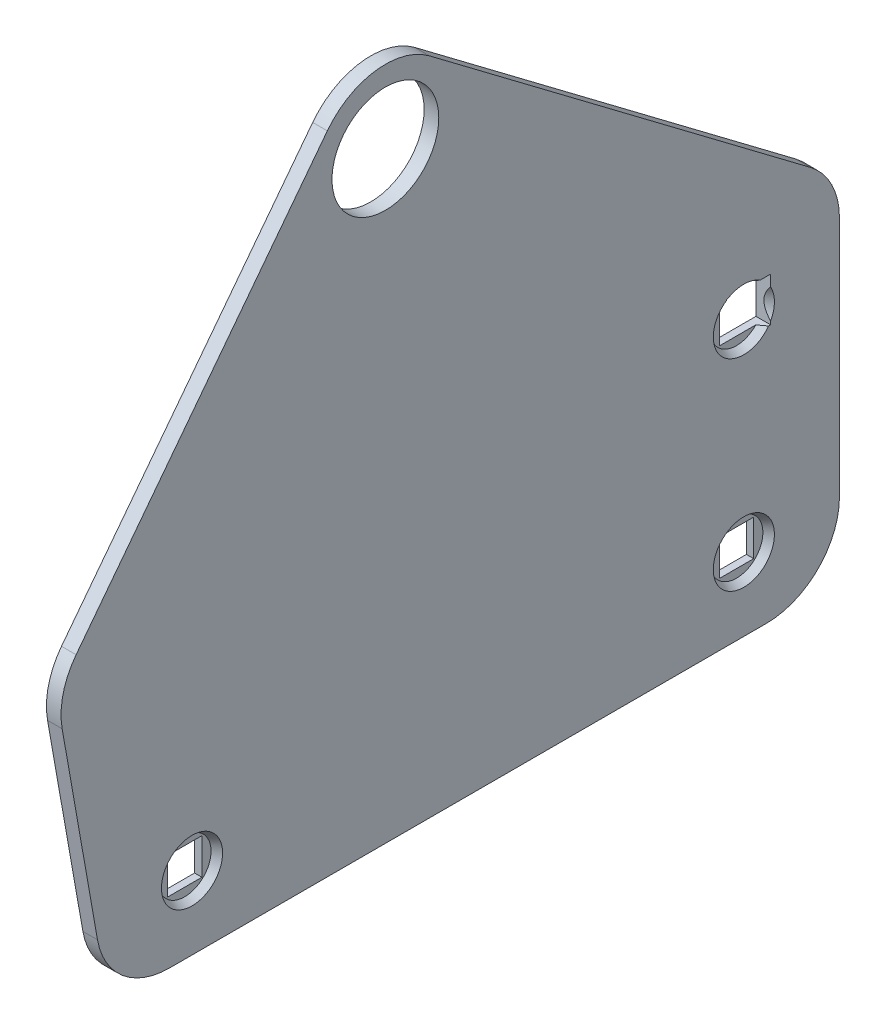
from build123d import *

# Parameters (mm, degrees)
SKETCH1_R           = 3.65
SKETCH1_W           = 3
SKETCH1_H           = 3
SKETCH1_W_2         = 2.35
SKETCH1_H_2         = 2.46
BOSS_EXTRUDE1_DEPTH = 1
SKETCH3_R           = 2.09
CUT_EXTRUDE1_DEPTH  = 0.5
CUT_EXTRUDE1_TAPER  = 30


with BuildPart() as part:
    # Sketch1 → Boss-Extrude1 (new body)
    with BuildSketch(Plane(origin=(0, 0, 0), x_dir=(0, 0, -1), z_dir=(1, 0, 0))):
        with BuildLine():
            Line((-20.402250922, 0), (20.402250922, 0))
            ThreePointArc((20.402250922, 0), (23.937784828, 1.464466094), (25.402250922, 5))
            Line((25.402250922, 5), (25.402250922, 21.50709196))
            ThreePointArc((25.402250922, 21.50709196), (24.87692273, 23.738081025), (23.411326038, 25.50026951))
            Line((23.411326038, 25.50026951), (-2.635195634, 45.127731407))
            ThreePointArc((-2.635195634, 45.127731407), (-6.321071977, 46.088536103), (-9.61416456, 44.174281334))
            Line((-9.61416456, 44.174281334), (-26.788641191, 21.74435991))
            ThreePointArc((-26.788641191, 21.74435991), (-27.676067974, 19.890565251), (-27.742786146, 17.836391544))
            Line((-27.742786146, 17.836391544), (-25.326289687, 4.131759112))
            ThreePointArc((-25.326289687, 4.131759112), (-23.61618897, 1.169777784), (-20.402250922, 0))
        make_face()
        with Locations((-5.64427075, 41.134553857)):
            Circle(SKETCH1_R, mode=Mode.SUBTRACT)
        with Locations((19.19182941, 19.04)):
            Rectangle(SKETCH1_W, SKETCH1_H, mode=Mode.SUBTRACT)
        with Locations((18.865, 5)):
            Rectangle(SKETCH1_W_2, SKETCH1_H_2, mode=Mode.SUBTRACT)
        with Locations((-18.865, 5)):
            Rectangle(SKETCH1_W_2, SKETCH1_H_2, mode=Mode.SUBTRACT)
    extrude(amount=BOSS_EXTRUDE1_DEPTH)

    # Sketch3 → Cut-Extrude1 (cut)
    with BuildSketch(Plane(origin=(1, 0, 0), x_dir=(0, 0, -1), z_dir=(1, 0, 0))):
        with Locations((-18.865, 5)):
            Circle(SKETCH3_R)
        with Locations((18.865, 5)):
            Circle(SKETCH3_R)
        with Locations((18.865, 18.77)):
            Circle(SKETCH3_R)
    extrude(amount=-CUT_EXTRUDE1_DEPTH, taper=CUT_EXTRUDE1_TAPER, mode=Mode.SUBTRACT)


solid = part.part
